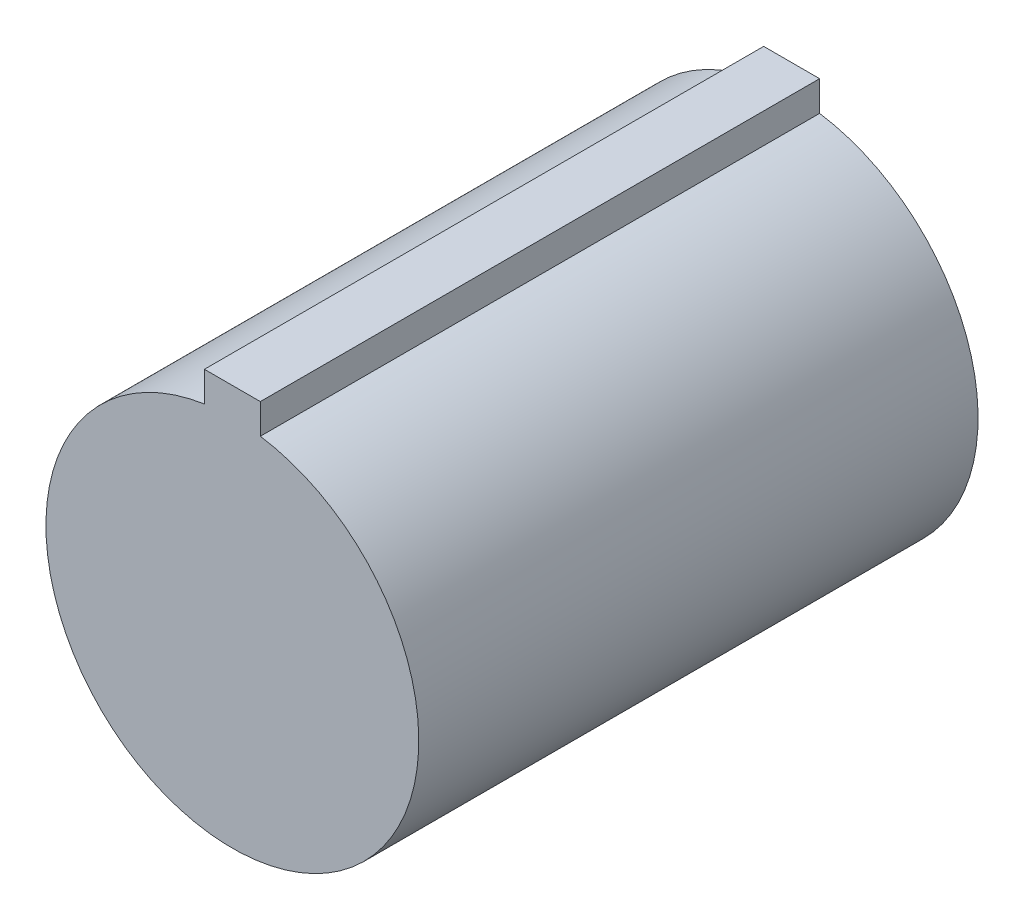
from build123d import *

# Parameters (mm, degrees)
SKETCH1_R           = 50.8
BOSS_EXTRUDE1_DEPTH = 76.2
BOSS_EXTRUDE2_DEPTH = 152.4


with BuildPart() as part:
    # Sketch1 → Boss-Extrude1 (new body, symmetric)
    with BuildSketch(Plane.XY):
        Circle(SKETCH1_R)
    extrude(amount=BOSS_EXTRUDE1_DEPTH, both=True)

    # Sketch2 → Boss-Extrude2 (add, through all)
    with BuildSketch(Plane.XY.offset(76.2)):
        with BuildLine():
            Line((7.62, 50.225248631), (7.62, 58.42))
            Line((7.62, 58.42), (-7.62, 58.42))
            Line((-7.62, 58.42), (-7.62, 50.225248631))
            ThreePointArc((-7.62, 50.225248631), (0, 50.8), (7.62, 50.225248631))
        make_face()
    extrude(amount=-BOSS_EXTRUDE2_DEPTH)


solid = part.part
